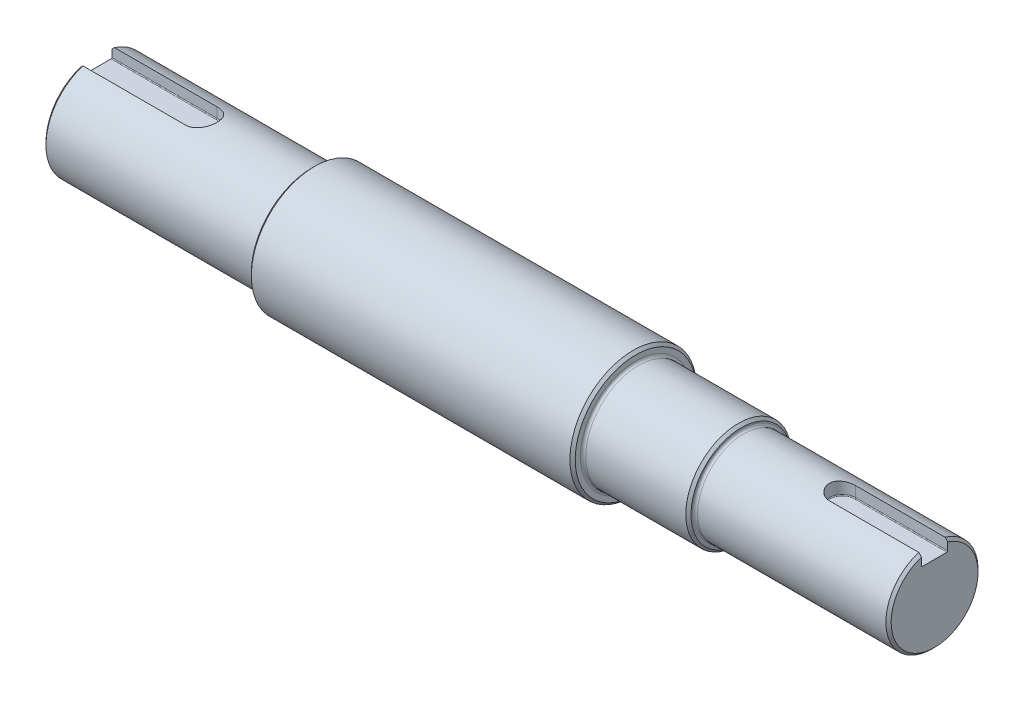
from build123d import *

# Parameters (mm, degrees)
CUT_EXTRUDE1_DEPTH = 5
FILLET1_R          = 0.3
CUT_EXTRUDE2_DEPTH = 5
FILLET2_R          = 0.3
CHAMFER1_SIZE      = 1
FILLET3_R          = 1


with BuildPart() as part:
    # Sketch1 → Revolve1 (revolve)
    with BuildSketch(Plane.XY):
        Polygon((-150, 0), (-150, 20), (-68, 20), (-68, 24), (55, 24), (55, 20), (95, 20), (95, 17.5), (168.5, 17.5), (168.5, 0), (34, 0), align=None)
    revolve(axis=Axis((-150, 0, 0), (1, 0, 0)))

    # Sketch2 → Cut-Extrude1 (cut)
    with BuildSketch(Plane(origin=(0, 20, 0), x_dir=(1, 0, 0), z_dir=(0, 1, 0))):
        with BuildLine():
            Line((-150, 6), (-150, -6))
            Line((-150, -6), (-110, -6))
            ThreePointArc((-110, -6), (-104, 0), (-110, 6))
            Line((-110, 6), (-150, 6))
        make_face()
    extrude(amount=-CUT_EXTRUDE1_DEPTH, mode=Mode.SUBTRACT)

    # Fillet1
    fillet1_edges = [part.edges().sort_by_distance(p)[0] for p in [
        (-130, 15, 6),
        (-104, 15, 0),
        (-130, 15, -6),
    ]]
    fillet(fillet1_edges, radius=FILLET1_R)

    # Sketch3 → Cut-Extrude2 (cut)
    with BuildSketch(Plane(origin=(0, 17.5, 0), x_dir=(1, 0, 0), z_dir=(0, 1, 0))):
        with BuildLine():
            Line((168.5, -5), (168.5, 5))
            Line((168.5, 5), (133.5, 5))
            ThreePointArc((133.5, 5), (128.5, 0), (133.5, -5))
            Line((133.5, -5), (168.5, -5))
        make_face()
    extrude(amount=-CUT_EXTRUDE2_DEPTH, mode=Mode.SUBTRACT)

    # Fillet2
    fillet2_edges = [part.edges().sort_by_distance(p)[0] for p in [
        (128.5, 12.5, 0),
        (151, 12.5, -5),
        (151, 12.5, 5),
    ]]
    fillet(fillet2_edges, radius=FILLET2_R)

    # Chamfer1
    chamfer1_edges = [part.edges().sort_by_distance(p)[0] for p in [
        (95, -20, 0),
        (55, -24, 0),
        (-68, -24, 0),
        (-150, -20, 0),
        (168.5, -17.5, 0),
    ]]
    chamfer(chamfer1_edges, length=CHAMFER1_SIZE)

    # Fillet3
    fillet3_edges = [part.edges().sort_by_distance(p)[0] for p in [
        (55, -20, 0),
        (-68, -20, 0),
        (95, -17.5, 0),
    ]]
    fillet(fillet3_edges, radius=FILLET3_R)


solid = part.part
